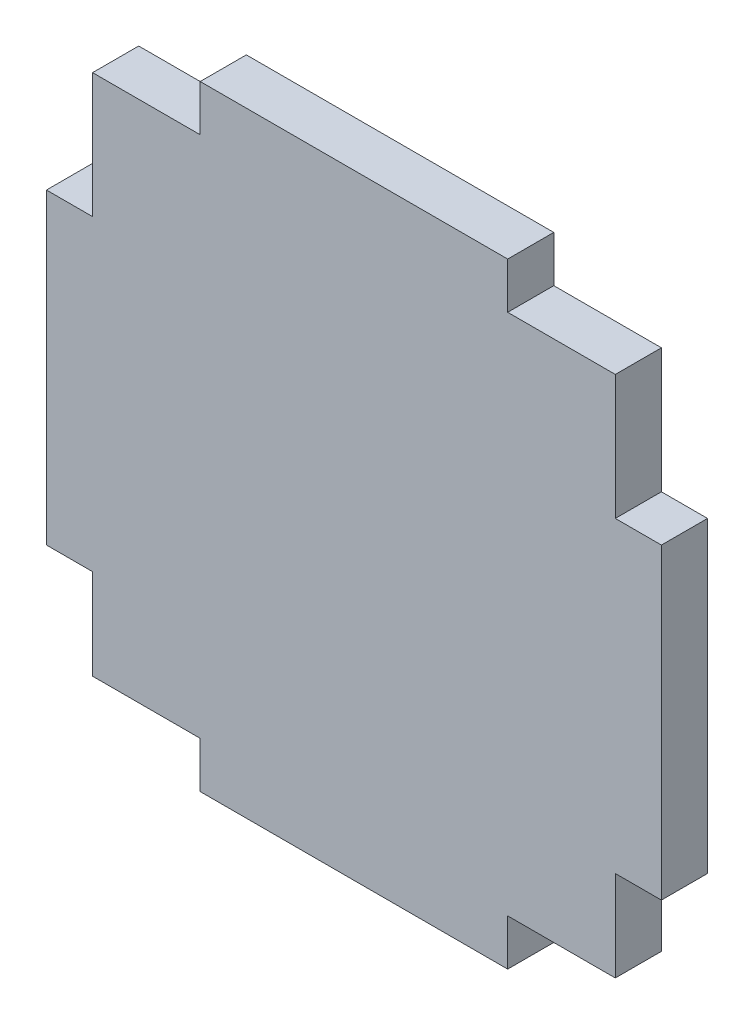
from build123d import *

# Parameters (mm, degrees)
SALIENTE_EXTRUIR1_DEPTH = 3


with BuildPart() as part:
    # Croquis1 → Saliente-Extruir1 (new body)
    with BuildSketch(Plane.XY):
        Polygon((83.773892479, -19.698612624), (83.773892479, -16.698612624), (103.773892479, -16.698612624), (103.773892479, -19.698612624), (110.773892479, -19.698612624), (110.773892479, -27.810520665), (113.773892479, -27.810520665), (113.773892479, -47.810520665), (110.773892479, -47.810520665), (110.773892479, -53.698612624), (103.773892479, -53.698612624), (103.773892479, -56.698612624), (83.773892479, -56.698612624), (83.773892479, -53.698612624), (76.773892479, -53.698612624), (76.773892479, -47.810520665), (73.773892479, -47.810520665), (73.773892479, -27.810520665), (76.773892479, -27.810520665), (76.773892479, -19.698612624), align=None)
    extrude(amount=SALIENTE_EXTRUIR1_DEPTH)


solid = part.part
